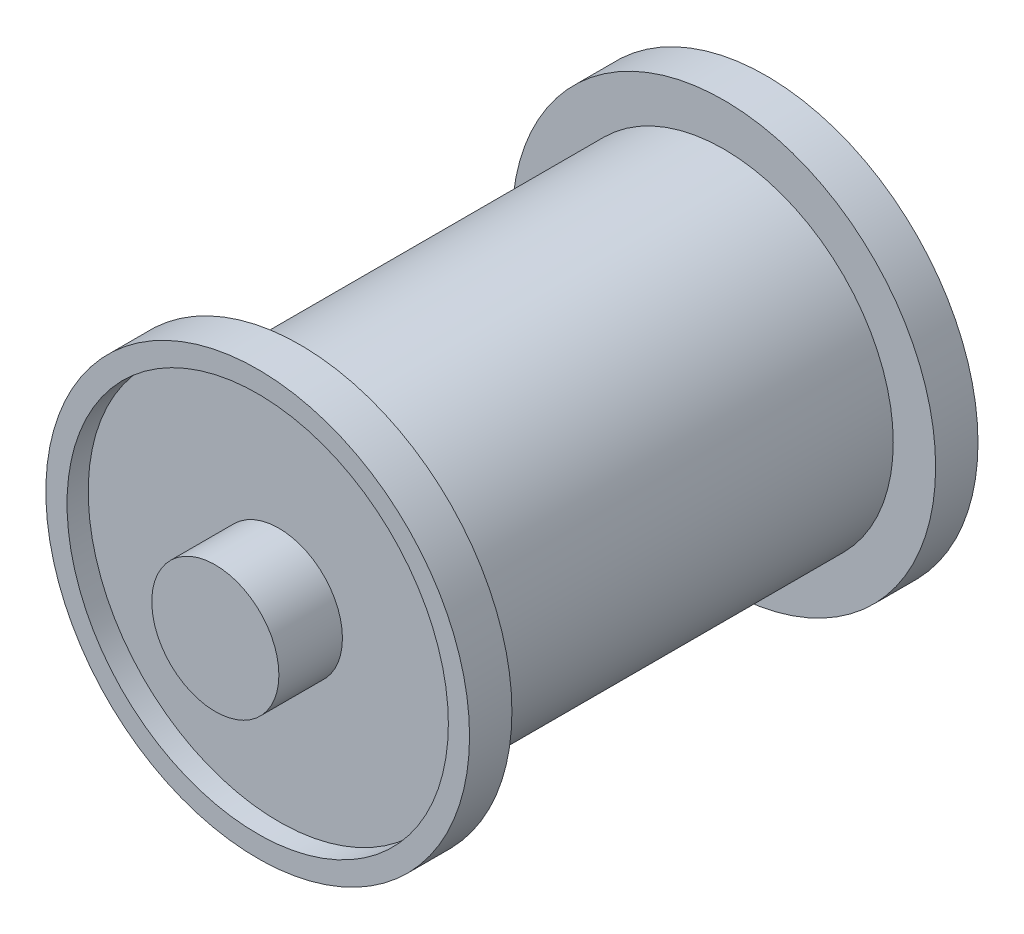
from build123d import *

# Parameters (mm, degrees)
CROQUIS1_R     = 10
EXTRUIR1_DEPTH = 2
VACIADO1_T     = -1
CROQUIS2_R     = 8
EXTRUIR2_DEPTH = 10
CROQUIS4_R     = 3
EXTRUIR4_DEPTH = 3


with BuildPart() as part:
    # Croquis1 → Extruir1 (new body)
    with BuildSketch(Plane.XY):
        Circle(CROQUIS1_R)
    extrude(amount=EXTRUIR1_DEPTH)

    # Vaciado1
    vaciado1_openings = [part.faces().sort_by_distance(p)[0] for p in [
        (0, 0, 2),
    ]]
    offset(amount=VACIADO1_T, openings=vaciado1_openings, kind=Kind.INTERSECTION)

    # Croquis2 → Extruir2 (add)
    with BuildSketch(Plane(origin=(0, 0, 0), x_dir=(-1, 0, 0), z_dir=(0, 0, -1))):
        with Locations(Location((0, 0, 0), (0, 0, 180))):  # turned: the seam where the file's is
            Circle(CROQUIS2_R)
    extrude(amount=EXTRUIR2_DEPTH)

    # Simetría3: part across plane


with BuildPart() as part_1:
    add(part.part)
    add(part.part.mirror(Plane(origin=(0, 0, -10), x_dir=(1, 0, 0), z_dir=(0, 0, -1))))

    # Croquis4 → Extruir4 (add)
    with BuildSketch(Plane.XY.offset(1)):
        Circle(CROQUIS4_R)
    extrude(amount=EXTRUIR4_DEPTH)


solid = part_1.part
